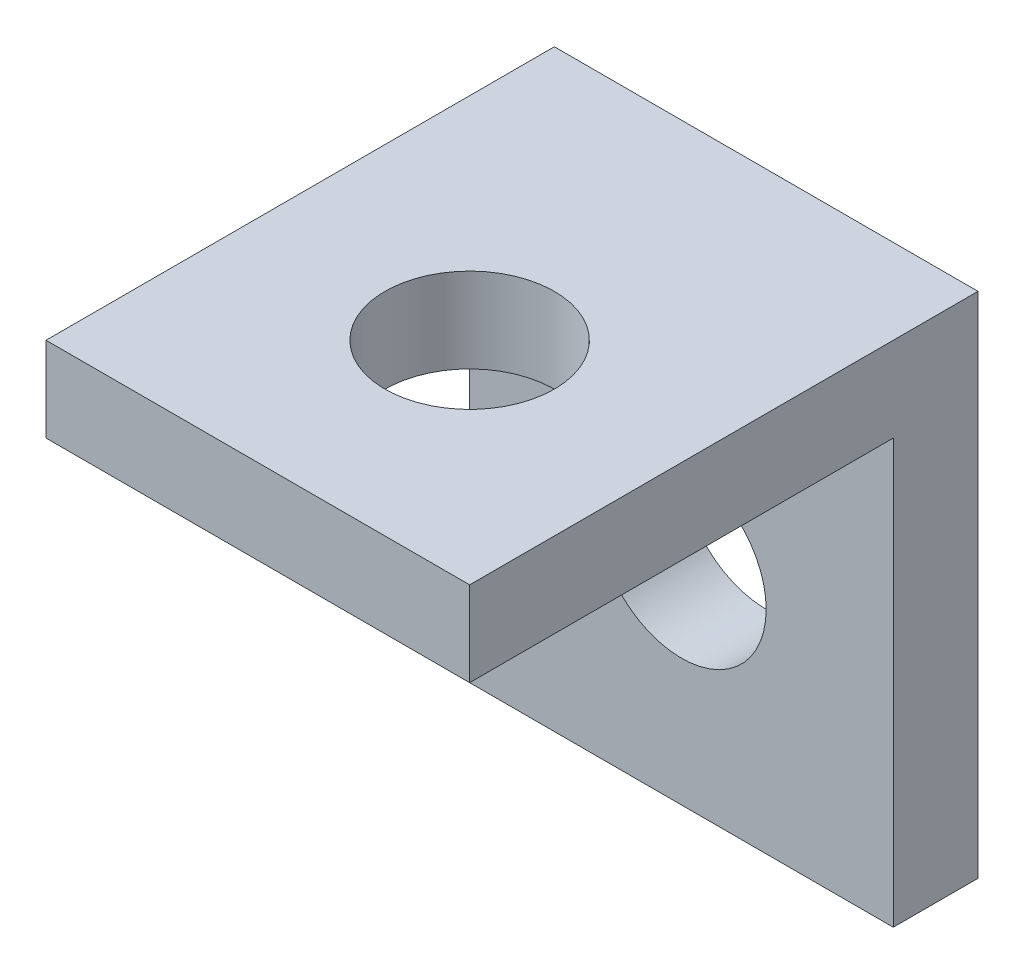
from build123d import *

# Parameters (mm, degrees)
SKETCH1_W           = 5
SKETCH1_H           = 5
BOSS_EXTRUDE1_DEPTH = 1
SKETCH2_W           = 5
SKETCH2_H           = 1
BOSS_EXTRUDE2_DEPTH = 5
SKETCH3_W           = 5
SKETCH3_H           = 1
BOSS_EXTRUDE3_DEPTH = 1
SKETCH4_R           = 1
CUT_EXTRUDE1_DEPTH  = 1
SKETCH5_R           = 1
CUT_EXTRUDE2_DEPTH  = 1


with BuildPart() as part:
    # Sketch1 → Boss-Extrude1 (new body)
    with BuildSketch(Plane.XY):
        with Locations((-2.841614907, 1.055900621)):
            Rectangle(SKETCH1_W, SKETCH1_H)
    extrude(amount=BOSS_EXTRUDE1_DEPTH)

    # Sketch2 → Boss-Extrude2 (add)
    with BuildSketch(Plane.XY.offset(1)):
        with Locations((-2.841614907, 3.055900621)):
            Rectangle(SKETCH2_W, SKETCH2_H)
    extrude(amount=BOSS_EXTRUDE2_DEPTH)

    # Sketch3 → Boss-Extrude3 (add)
    with BuildSketch(Plane.XZ.offset(1.444099379)):
        with Locations((-2.841614907, 0.5)):
            Rectangle(SKETCH3_W, SKETCH3_H)
    extrude(amount=BOSS_EXTRUDE3_DEPTH)

    # Sketch4 → Cut-Extrude1 (cut)
    with BuildSketch(Plane.XY.offset(1)):
        with Locations((-2.841614907, 0.055900621)):
            Circle(SKETCH4_R)
    extrude(amount=-CUT_EXTRUDE1_DEPTH, mode=Mode.SUBTRACT)

    # Sketch5 → Cut-Extrude2 (cut)
    with BuildSketch(Plane.XZ.offset(-2.555900621)):
        with Locations((-2.841614907, 3.5)):
            Circle(SKETCH5_R)
    extrude(amount=-CUT_EXTRUDE2_DEPTH, mode=Mode.SUBTRACT)


solid = part.part
